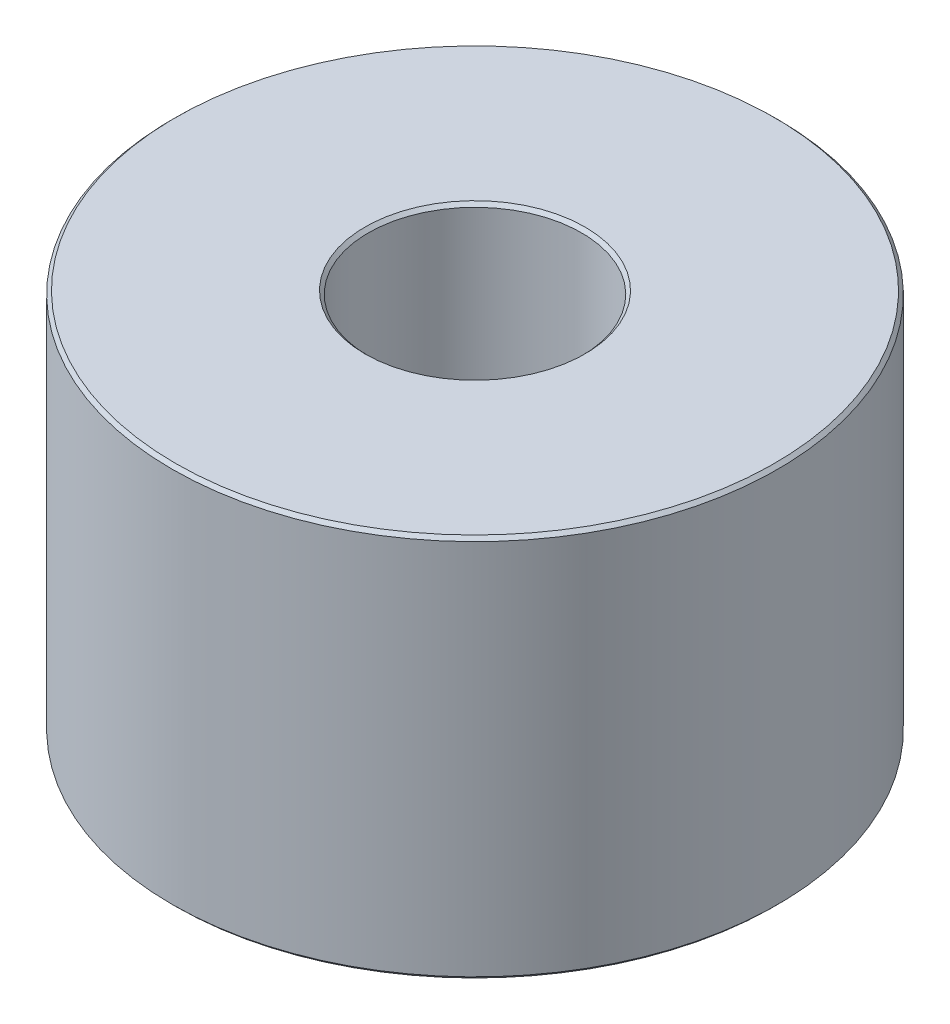
from build123d import *

# Parameters (mm, degrees)
MAIN_DIMENSIONS_SKETCH_R   = 9
MAIN_DIMENSIONS_SKETCH_R_2 = 3.16865
BODY_DEPTH                 = 10
LIP_START                  = -1.4
SKETCH1_3_R                = 9
SKETCH1_3_R_2              = 5.5
LIP_DEPTH                  = 1.4
BREAK_EDGES_SIZE           = 0.1


with BuildPart() as part:
    # main_dimensions_sketch → body (new body)
    with BuildSketch(Plane(origin=(0, 0, 0), x_dir=(1, 0, 0), z_dir=(0, 1, 0))):
        Circle(MAIN_DIMENSIONS_SKETCH_R)
        Circle(MAIN_DIMENSIONS_SKETCH_R_2, mode=Mode.SUBTRACT)
    extrude(amount=BODY_DEPTH)

    # Sketch1_3 → lip (add)
    with BuildSketch(Plane(origin=(0, 0, 0), x_dir=(1, 0, 0), z_dir=(0, 1, 0)).offset(LIP_START)):
        Circle(SKETCH1_3_R)
        Circle(SKETCH1_3_R_2, mode=Mode.SUBTRACT)
    extrude(amount=LIP_DEPTH)

    # break_edges
    break_edges_edges = [part.edges().sort_by_distance(p)[0] for p in [
        (-9, -1.4, 0),
        (-5.5, -1.4, 0),
        (-3.16865, 10, 0),
        (-9, 10, 0),
        (-3.16865, 0, 0),
    ]]
    chamfer(break_edges_edges, length=BREAK_EDGES_SIZE)


solid = part.part
